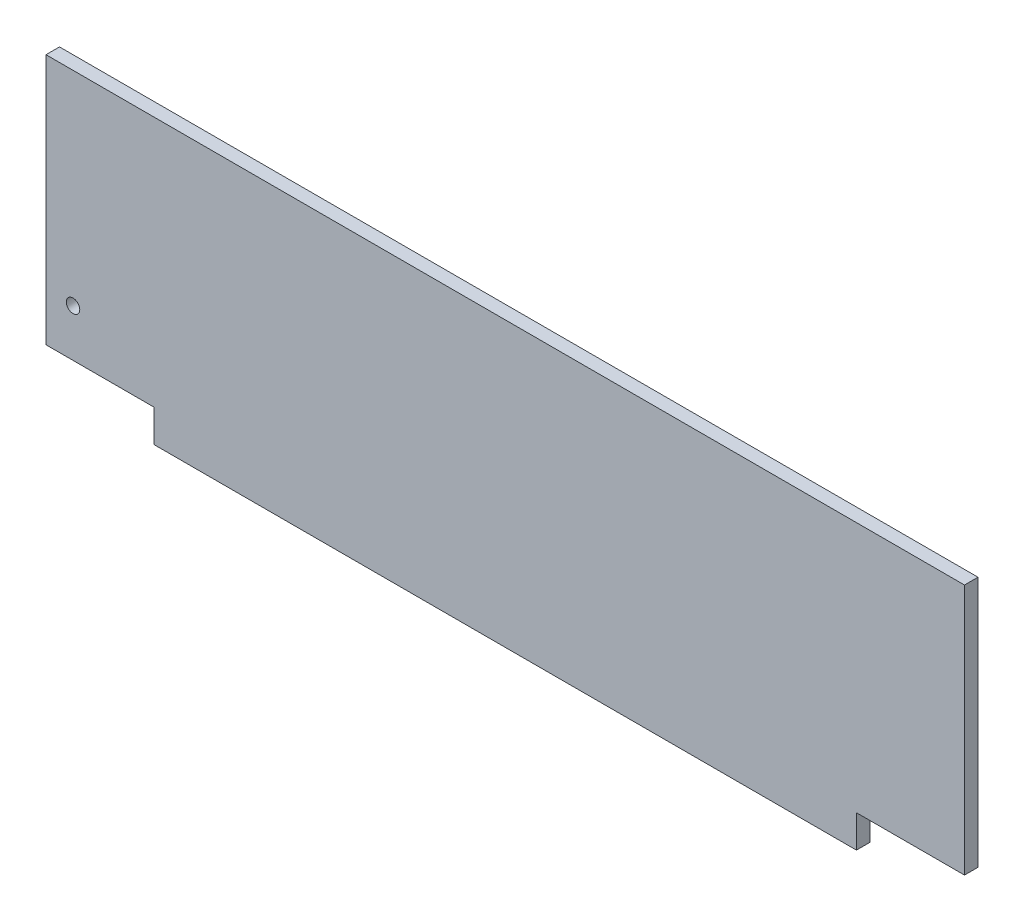
from build123d import *

# Parameters (mm, degrees)
ESQUISSE1_W             = 680
ESQUISSE1_H             = 210
BOSS_EXTRU_1_DEPTH      = 10
ESQUISSE2_W             = 80
ESQUISSE2_H             = 24
ENL_V_MAT_EXTRU_1_DEPTH = 11
ESQUISSE3_R             = 5
ENL_V_MAT_EXTRU_2_DEPTH = 11


with BuildPart() as part:
    # Esquisse1 → Boss.-Extru.1 (new body)
    with BuildSketch(Plane.XY):
        Rectangle(ESQUISSE1_W, ESQUISSE1_H)
    extrude(amount=BOSS_EXTRU_1_DEPTH)

    # Esquisse2 → Enlèv. mat.-Extru.1 (cut, through all)
    with BuildSketch(Plane.XY.offset(10)):
        with Locations((-300, -93)):
            Rectangle(ESQUISSE2_W, ESQUISSE2_H)
        with Locations((300, -93)):
            Rectangle(ESQUISSE2_W, ESQUISSE2_H)
    extrude(amount=-ENL_V_MAT_EXTRU_1_DEPTH, mode=Mode.SUBTRACT)

    # Esquisse3 → Enlèv. mat.-Extru.2 (cut, through all)
    with BuildSketch(Plane.XY.offset(10)):
        with Locations((-320, -46)):
            Circle(ESQUISSE3_R)
    extrude(amount=-ENL_V_MAT_EXTRU_2_DEPTH, mode=Mode.SUBTRACT)


solid = part.part
